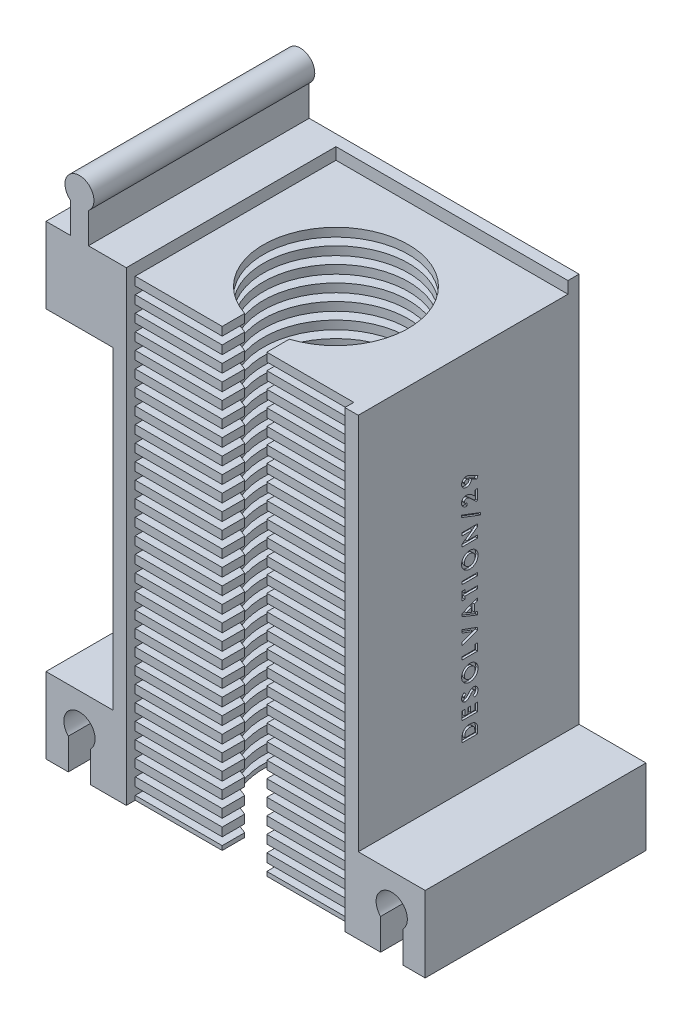
from build123d import *

# Parameters (mm, degrees)
ESQUISSE1_W              = 55
ESQUISSE1_H              = 106.55
BOSS_EXTRU_2_DEPTH       = 49.5
ESQUISSE6_W              = 49
ESQUISSE6_H              = 101.75
ENL_V_MAT_EXTRU_2_DEPTH  = 47
ESQUISSE7_W              = 49
ESQUISSE7_H              = 1.9
BOSS_EXTRU_3_DEPTH       = 45
ESQUISSE8_R              = 16.25
ENL_V_MAT_EXTRU_4_DEPTH  = 107.55
ESQUISSE9_W              = 10
ESQUISSE9_H              = 5.038353904
ENL_V_MAT_EXTRU_5_DEPTH  = 107.55
ESQUISSE11_W             = 55
ESQUISSE11_H             = 49.5
ENL_V_MAT_EXTRU_6_DEPTH  = 4.8
ESQUISSE14_W             = 15
ESQUISSE14_H             = 17.95
BOSS_EXTRU_5_DEPTH       = 49.5
ESQUISSE15_W             = 15
ESQUISSE15_H             = 17.95
BOSS_EXTRU_6_DEPTH       = 49.5
ESQUISSE16_W             = 15
ESQUISSE16_H             = 17
BOSS_EXTRU_7_DEPTH       = 49.5
ESQUISSE17_W             = 15
ESQUISSE17_H             = 17
BOSS_EXTRU_8_DEPTH       = 49.5
ENL_V_MAT_EXTRU_8_DEPTH  = 50.5
BOSS_EXTRU_9_DEPTH       = 49.5
ENL_V_MAT_EXTRU_10_DEPTH = 0.95
ESQUISSE22_W             = 5
ESQUISSE22_H             = 49.5
ENL_V_MAT_EXTRU_11_DEPTH = 0.95
BOSS_EXTRU_10_DEPTH      = 3.6
ESQUISSE24_W             = 49
ESQUISSE24_H             = 1.7
ENL_V_MAT_EXTRU_12_DEPTH = 45
ESQUISSE25_W             = 15
ESQUISSE25_H             = 49.5
ENL_V_MAT_EXTRU_13_DEPTH = 3.6
ESQUISSE26_W             = 5.5
ESQUISSE26_H             = 49.5
BOSS_EXTRU_11_DEPTH      = 3.6
ESQUISSE27_W             = 3.5
ESQUISSE27_H             = 0.628205128
ENL_V_MAT_EXTRU_14_DEPTH = 0.5
ESQUISSE28_W             = 15
ESQUISSE28_H             = 49.5
ENL_V_MAT_EXTRU_15_DEPTH = 30.651737691
ESQUISSE29_W             = 47
ESQUISSE29_H             = 2.65
ENL_V_MAT_EXTRU_16_DEPTH = 68


with BuildPart() as part:
    # Esquisse1 → Boss.-Extru.2 (new body)
    with BuildSketch(Plane.XY):
        with Locations((7.352262443, -28.968325792)):
            Rectangle(ESQUISSE1_W, ESQUISSE1_H)
    extrude(amount=BOSS_EXTRU_2_DEPTH)

    # Esquisse6 → Enlèv. mat.-Extru.2 (cut)
    with BuildSketch(Plane.XY.offset(49.5)):
        with Locations((7.352262443, -31.368325792)):
            Rectangle(ESQUISSE6_W, ESQUISSE6_H)
    extrude(amount=-ENL_V_MAT_EXTRU_2_DEPTH, mode=Mode.SUBTRACT)

    # Esquisse7 → Boss.-Extru.3 (add)
    with BuildSketch(Plane.XY.offset(2.5)):
        with Locations((7.352262443, -81.293325792)):
            Rectangle(ESQUISSE7_W, ESQUISSE7_H)
        with Locations((7.352262443, -77.693325792)):
            Rectangle(ESQUISSE7_W, ESQUISSE7_H)
        with Locations((7.352262443, -74.093325792)):
            Rectangle(ESQUISSE7_W, ESQUISSE7_H)
        with Locations((7.352262443, -70.493325792)):
            Rectangle(ESQUISSE7_W, ESQUISSE7_H)
        with Locations((7.352262443, -66.893325792)):
            Rectangle(ESQUISSE7_W, ESQUISSE7_H)
        with Locations((7.352262443, -63.293325792)):
            Rectangle(ESQUISSE7_W, ESQUISSE7_H)
        with Locations((7.352262443, -59.693325792)):
            Rectangle(ESQUISSE7_W, ESQUISSE7_H)
        with Locations((7.352262443, -56.093325792)):
            Rectangle(ESQUISSE7_W, ESQUISSE7_H)
        with Locations((7.352262443, -52.493325792)):
            Rectangle(ESQUISSE7_W, ESQUISSE7_H)
        with Locations((7.352262443, -48.893325792)):
            Rectangle(ESQUISSE7_W, ESQUISSE7_H)
        with Locations((7.352262443, -45.293325792)):
            Rectangle(ESQUISSE7_W, ESQUISSE7_H)
        with Locations((7.352262443, -41.693325792)):
            Rectangle(ESQUISSE7_W, ESQUISSE7_H)
        with Locations((7.352262443, -38.093325792)):
            Rectangle(ESQUISSE7_W, ESQUISSE7_H)
        with Locations((7.352262443, -34.493325792)):
            Rectangle(ESQUISSE7_W, ESQUISSE7_H)
        with Locations((7.352262443, -30.893325792)):
            Rectangle(ESQUISSE7_W, ESQUISSE7_H)
        with Locations((7.352262443, -27.293325792)):
            Rectangle(ESQUISSE7_W, ESQUISSE7_H)
        with Locations((7.352262443, -23.693325792)):
            Rectangle(ESQUISSE7_W, ESQUISSE7_H)
        with Locations((7.352262443, -20.093325792)):
            Rectangle(ESQUISSE7_W, ESQUISSE7_H)
        with Locations((7.352262443, -16.493325792)):
            Rectangle(ESQUISSE7_W, ESQUISSE7_H)
        with Locations((7.352262443, -12.893325792)):
            Rectangle(ESQUISSE7_W, ESQUISSE7_H)
        with Locations((7.352262443, -9.293325792)):
            Rectangle(ESQUISSE7_W, ESQUISSE7_H)
        with Locations((7.352262443, -5.693325792)):
            Rectangle(ESQUISSE7_W, ESQUISSE7_H)
        with Locations((7.352262443, -2.093325792)):
            Rectangle(ESQUISSE7_W, ESQUISSE7_H)
        with Locations((7.352262443, 1.506674208)):
            Rectangle(ESQUISSE7_W, ESQUISSE7_H)
        with Locations((7.352262443, 5.106674208)):
            Rectangle(ESQUISSE7_W, ESQUISSE7_H)
        with Locations((7.352262443, 8.706674208)):
            Rectangle(ESQUISSE7_W, ESQUISSE7_H)
        with Locations((7.352262443, 12.306674208)):
            Rectangle(ESQUISSE7_W, ESQUISSE7_H)
        with Locations((7.352262443, 15.906674208)):
            Rectangle(ESQUISSE7_W, ESQUISSE7_H)
        with Locations((7.352262443, 19.506674208)):
            Rectangle(ESQUISSE7_W, ESQUISSE7_H)
    extrude(amount=BOSS_EXTRU_3_DEPTH)

    # Esquisse8 → Enlèv. mat.-Extru.4 (cut, through all)
    with BuildSketch(Plane.XZ.offset(82.243325792)):
        with Locations((7.352262443, 27)):
            Circle(ESQUISSE8_R)
    extrude(amount=-ENL_V_MAT_EXTRU_4_DEPTH, mode=Mode.SUBTRACT)

    # Esquisse9 → Enlèv. mat.-Extru.5 (cut, through all)
    with BuildSketch(Plane.XZ.offset(82.243325792)):
        with Locations((7.352262443, 44.980823048)):
            Rectangle(ESQUISSE9_W, ESQUISSE9_H)
    extrude(amount=-ENL_V_MAT_EXTRU_5_DEPTH, mode=Mode.SUBTRACT)

    # Esquisse11 → Enlèv. mat.-Extru.6 (cut)
    with BuildSketch(Plane(origin=(0, 24.306674208, 0), x_dir=(1, 0, 0), z_dir=(0, 1, 0))):
        with Locations((7.352262443, -24.75)):
            Rectangle(ESQUISSE11_W, ESQUISSE11_H)
    extrude(amount=-ENL_V_MAT_EXTRU_6_DEPTH, mode=Mode.SUBTRACT)

    # Esquisse14 → Boss.-Extru.5 (add)
    with BuildSketch(Plane.XY.offset(49.5)):
        with Locations((42.352262443, -73.268325792)):
            Rectangle(ESQUISSE14_W, ESQUISSE14_H)
    extrude(amount=-BOSS_EXTRU_5_DEPTH)

    # Esquisse15 → Boss.-Extru.6 (add)
    with BuildSketch(Plane.XY.offset(49.5)):
        with Locations((-27.647737557, -73.268325792)):
            Rectangle(ESQUISSE15_W, ESQUISSE15_H)
    extrude(amount=-BOSS_EXTRU_6_DEPTH)

    # Esquisse16 → Boss.-Extru.7 (add)
    with BuildSketch(Plane.XY.offset(49.5)):
        with Locations((42.352262443, 11.006674208)):
            Rectangle(ESQUISSE16_W, ESQUISSE16_H)
    extrude(amount=-BOSS_EXTRU_7_DEPTH)

    # Esquisse17 → Boss.-Extru.8 (add)
    with BuildSketch(Plane.XY.offset(49.5)):
        with Locations((-27.647737557, 11.006674208)):
            Rectangle(ESQUISSE17_W, ESQUISSE17_H)
    extrude(amount=-BOSS_EXTRU_8_DEPTH)

    # Esquisse18 → Enlèv. mat.-Extru.8 (cut, through all)
    with BuildSketch(Plane.XY.offset(49.5)):
        with BuildLine():
            Line((44.852262443, -74.343325792), (44.852262443, -82.243325792))
            Line((44.852262443, -82.243325792), (39.852262443, -82.243325792))
            Line((39.852262443, -82.243325792), (39.852262443, -74.343325792))
            ThreePointArc((39.852262443, -74.343325792), (42.352262443, -68.393836049), (44.852262443, -74.343325792))
        make_face()
        with BuildLine():
            Line((-30.147737557, -82.243325792), (-25.147737557, -82.243325792))
            Line((-25.147737557, -82.243325792), (-25.147737557, -74.343325792))
            ThreePointArc((-25.147737557, -74.343325792), (-27.647737557, -68.393836049), (-30.147737557, -74.343325792))
            Line((-30.147737557, -74.343325792), (-30.147737557, -82.243325792))
        make_face()
    extrude(amount=-ENL_V_MAT_EXTRU_8_DEPTH, mode=Mode.SUBTRACT)

    # Esquisse20 → Boss.-Extru.9 (add)
    with BuildSketch(Plane.XY.offset(49.5)):
        with BuildLine():
            Line((-29.647737557, 29.946674208), (-29.647737557, 19.506674208))
            Line((-29.647737557, 19.506674208), (-25.647737557, 19.506674208))
            Line((-25.647737557, 19.506674208), (-25.647737557, 29.946674208))
            ThreePointArc((-25.647737557, 29.946674208), (-27.647737557, 35.7584119), (-29.647737557, 29.946674208))
        make_face()
        with BuildLine():
            Line((40.352262443, 19.506674208), (40.352262443, 29.946674208))
            ThreePointArc((40.352262443, 29.946674208), (42.352262443, 35.7584119), (44.352262443, 29.946674208))
            Line((44.352262443, 29.946674208), (44.352262443, 19.506674208))
            Line((44.352262443, 19.506674208), (40.352262443, 19.506674208))
        make_face()
    extrude(amount=-BOSS_EXTRU_9_DEPTH)

    # Esquisse10 → Enlèv. mat.-Extru.10 (cut)
    with BuildSketch(Plane.XZ.offset(82.243325792)):
        with BuildLine():
            Line((31.852262443, 47.5), (12.352262443, 47.5))
            Line((12.352262443, 47.5), (12.352262443, 42.461646096))
            ThreePointArc((12.352262443, 42.461646096), (7.352262443, 10.75), (2.352262443, 42.461646096))
            Line((2.352262443, 42.461646096), (2.352262443, 47.5))
            Line((2.352262443, 47.5), (-17.147737557, 47.5))
            Line((-17.147737557, 47.5), (-17.147737557, 49.5))
            Line((-17.147737557, 49.5), (-20.147737557, 49.5))
            Line((-20.147737557, 49.5), (-20.147737557, 0))
            Line((-20.147737557, 0), (34.852262443, 0))
            Line((34.852262443, 0), (34.852262443, 49.5))
            Line((34.852262443, 49.5), (31.852262443, 49.5))
            Line((31.852262443, 49.5), (31.852262443, 47.5))
        make_face()
    extrude(amount=-ENL_V_MAT_EXTRU_10_DEPTH, mode=Mode.SUBTRACT)

    # Esquisse22 → Enlèv. mat.-Extru.11 (cut)
    with BuildSketch(Plane.XZ.offset(82.243325792)):
        with Locations((47.352262443, 24.75)):
            Rectangle(ESQUISSE22_W, ESQUISSE22_H)
        with Locations((37.352262443, 24.75)):
            Rectangle(ESQUISSE22_W, ESQUISSE22_H)
        with Locations((-32.647737557, 24.75)):
            Rectangle(ESQUISSE22_W, ESQUISSE22_H)
        with Locations((-22.647737557, 24.75)):
            Rectangle(ESQUISSE22_W, ESQUISSE22_H)
    extrude(amount=-ENL_V_MAT_EXTRU_11_DEPTH, mode=Mode.SUBTRACT)

    # Esquisse23 → Boss.-Extru.10 (add)
    with BuildSketch(Plane(origin=(0, 19.506674208, 0), x_dir=(1, 0, 0), z_dir=(0, 1, 0))):
        with BuildLine():
            Line((40.352262443, -49.5), (40.352262443, 0))
            Line((40.352262443, 0), (-25.647737557, 0))
            Line((-25.647737557, 0), (-25.647737557, -49.5))
            Line((-25.647737557, -49.5), (-17.147737557, -49.5))
            Line((-17.147737557, -49.5), (-17.147737557, -47.5))
            Line((-17.147737557, -47.5), (2.352262443, -47.5))
            Line((2.352262443, -47.5), (2.352262443, -42.461646096))
            ThreePointArc((2.352262443, -42.461646096), (7.352262443, -10.75), (12.352262443, -42.461646096))
            Line((12.352262443, -42.461646096), (12.352262443, -47.5))
            Line((12.352262443, -47.5), (31.852262443, -47.5))
            Line((31.852262443, -47.5), (31.852262443, -49.5))
            Line((31.852262443, -49.5), (40.352262443, -49.5))
        make_face()
    extrude(amount=BOSS_EXTRU_10_DEPTH)

    # Esquisse24 → Enlèv. mat.-Extru.12 (cut)
    with BuildSketch(Plane.XY.offset(47.5)):
        with Locations((7.352262443, 21.306674208)):
            Rectangle(ESQUISSE24_W, ESQUISSE24_H)
    extrude(amount=-ENL_V_MAT_EXTRU_12_DEPTH, mode=Mode.SUBTRACT)

    # Esquisse25 → Enlèv. mat.-Extru.13 (cut)
    with BuildSketch(Plane.XZ.offset(-2.506674208)):
        with Locations((-27.647737557, 24.75)):
            Rectangle(ESQUISSE25_W, ESQUISSE25_H)
        with Locations((42.352262443, 24.75)):
            Rectangle(ESQUISSE25_W, ESQUISSE25_H)
    extrude(amount=-ENL_V_MAT_EXTRU_13_DEPTH, mode=Mode.SUBTRACT)

    # Esquisse26 → Boss.-Extru.11 (add)
    with BuildSketch(Plane(origin=(0, 19.506674208, 0), x_dir=(1, 0, 0), z_dir=(0, 1, 0))):
        with Locations((-32.397737557, -24.75)):
            Rectangle(ESQUISSE26_W, ESQUISSE26_H)
        with Locations((47.102262443, -24.75)):
            Rectangle(ESQUISSE26_W, ESQUISSE26_H)
    extrude(amount=BOSS_EXTRU_11_DEPTH)

    # Esquisse27 → Enlèv. mat.-Extru.14 (cut)
    with BuildSketch(Plane(origin=(34.852262443, 0, 0), x_dir=(0, 0, -1), z_dir=(1, 0, 0))):
        with BuildLine():
            Line((-26.25, -54.768966817), (-26.25, -53.977400311))
            add(Edge.make_bspline(
                [(-26.25, -53.977400311), (-26.249578594, -53.915687085), (-26.248764011, -53.79639472), (-26.239233964, -53.623588275), (-26.225241045, -53.462779541), (-26.203820297, -53.314334816), (-26.178974202, -53.177711122), (-26.145644783, -53.053944802), (-26.107640591, -52.942138404), (-26.062804681, -52.841206053), (-26.010558183, -52.749060361), (-25.952352997, -52.661566177), (-25.886064826, -52.578893855), (-25.812970397, -52.499883605), (-25.731733047, -52.425554968), (-25.643698202, -52.354670132), (-25.547589281, -52.288964674), (-25.445710659, -52.226452461), (-25.337630589, -52.169918483), (-25.224269024, -52.120607434), (-25.106355489, -52.07929927), (-24.983764318, -52.045734248), (-24.856902477, -52.018979051), (-24.72551397, -52.000258979), (-24.589720442, -51.988686044), (-24.4976865, -51.987512066), (-24.450921474, -51.986915535)],
                knots=[0, 0, 0, 0, 0.000185117, 0.000357834, 0.000519065, 0.000669183, 0.000807653, 0.000935374, 0.001053334, 0.001161611, 0.001266144, 0.001370762, 0.001476536, 0.001583695, 0.001693351, 0.00180657, 0.001922483, 0.002042366, 0.002164984, 0.002288073, 0.002412914, 0.002539466, 0.002669135, 0.002801605, 0.002937385, 0.003077654, 0.003077654, 0.003077654, 0.003077654], degree=3))
            add(Edge.make_bspline(
                [(-24.450921474, -51.986915535), (-24.384932979, -51.988477575), (-24.255030763, -51.991552542), (-24.064400757, -52.017454346), (-23.881662884, -52.059346333), (-23.708246589, -52.118250271), (-23.545696172, -52.191275386), (-23.396878133, -52.278512063), (-23.262591281, -52.378681211), (-23.143504152, -52.490615844), (-23.04114743, -52.61181382), (-22.953485402, -52.737762852), (-22.884360039, -52.869690389), (-22.840513664, -52.985935833), (-22.813270001, -53.086737915), (-22.797083391, -53.175231737), (-22.782639367, -53.275819688), (-22.769738179, -53.389168755), (-22.761139953, -53.515267782), (-22.755119024, -53.654138111), (-22.750668347, -53.805597536), (-22.75022862, -53.910790215), (-22.75, -53.965481241)],
                knots=[0, 0, 0, 0, 0.000197895, 0.000389568, 0.000575968, 0.000759549, 0.000938093, 0.001109685, 0.001275991, 0.00143967, 0.001598838, 0.001751113, 0.001899136, 0.002044464, 0.002122868, 0.002212109, 0.002314138, 0.002427722, 0.002554253, 0.002693218, 0.002844719, 0.003008787, 0.003008787, 0.003008787, 0.003008787], degree=3))
            Line((-22.75, -53.965481241), (-22.75, -54.768966817))
            Line((-22.75, -54.768966817), (-26.25, -54.768966817))
        make_face()
        with BuildLine():
            Line((-25.621794872, -54.140761689), (-23.378205128, -54.140761689))
            Line((-23.378205128, -54.140761689), (-23.378205128, -53.812636689))
            add(Edge.make_bspline(
                [(-23.378205128, -53.812636689), (-23.378394152, -53.773601622), (-23.378757652, -53.698535563), (-23.383752105, -53.590024754), (-23.391862503, -53.489884036), (-23.403859003, -53.397982239), (-23.418293863, -53.314108086), (-23.436147882, -53.238567527), (-23.457859729, -53.171211673), (-23.483447361, -53.11148508), (-23.512661318, -53.05695602), (-23.546774213, -53.006439255), (-23.584684458, -52.957684422), (-23.627472703, -52.911592604), (-23.674581701, -52.867992226), (-23.726251594, -52.827140464), (-23.782325449, -52.788492273), (-23.843099544, -52.753039619), (-23.907932147, -52.720642798), (-23.976195242, -52.691903186), (-24.04845732, -52.668073807), (-24.124041919, -52.648268286), (-24.20360709, -52.634114996), (-24.286563503, -52.622405848), (-24.373239826, -52.61636944), (-24.432217292, -52.615540981), (-24.462139423, -52.615120664)],
                knots=[0, 0, 0, 0, 0.000117096, 0.00022518, 0.000325793, 0.00041841, 0.000503133, 0.000581017, 0.00065108, 0.000715155, 0.0007757, 0.00083637, 0.000897801, 0.000960813, 0.001024815, 0.001090185, 0.001158251, 0.001228957, 0.001301074, 0.001375555, 0.001450937, 0.001529162, 0.001609745, 0.001693235, 0.001780402, 0.001870171, 0.001870171, 0.001870171, 0.001870171], degree=3))
            add(Edge.make_bspline(
                [(-24.462139423, -52.615120664), (-24.507993301, -52.615954791), (-24.597404811, -52.617581276), (-24.727617239, -52.633364792), (-24.850078276, -52.658796641), (-24.964473331, -52.695843815), (-25.071529664, -52.741402153), (-25.169867721, -52.799330531), (-25.261099367, -52.866109794), (-25.314608967, -52.918947546), (-25.341346154, -52.945349029)],
                knots=[0, 0, 0, 0, 0.000137507, 0.000268129, 0.000392852, 0.000512141, 0.000628325, 0.00074112, 0.000853862, 0.000966454, 0.000966454, 0.000966454, 0.000966454], degree=3))
            add(Edge.make_bspline(
                [(-25.341346154, -52.945349029), (-25.364130624, -52.971381223), (-25.410665325, -53.024549032), (-25.466425797, -53.117894233), (-25.515416837, -53.220755809), (-25.554261268, -53.335486926), (-25.584981101, -53.460978759), (-25.606167818, -53.597978738), (-25.619782177, -53.7457532), (-25.6211096, -53.848127904), (-25.621794872, -53.900978035)],
                knots=[0, 0, 0, 0, 0.000103595, 0.000211582, 0.000324802, 0.000444978, 0.000574215, 0.000711958, 0.000860493, 0.001019003, 0.001019003, 0.001019003, 0.001019003], degree=3))
            Line((-25.621794872, -53.900978035), (-25.621794872, -54.140761689))
        make_face(mode=Mode.SUBTRACT)
        Polygon((-26.25, -50.470248869), (-26.25, -48.585633484), (-25.621794872, -48.585633484), (-25.621794872, -49.842043741), (-24.948717949, -49.842043741), (-24.948717949, -48.585633484), (-24.320512821, -48.585633484), (-24.320512821, -49.842043741), (-23.378205128, -49.842043741), (-23.378205128, -48.585633484), (-22.75, -48.585633484), (-22.75, -50.470248869), align=None)
        with BuildLine():
            Line((-25.782351763, -45.274095023), (-25.352564103, -45.743846625))
            add(Edge.make_bspline(
                [(-25.352564103, -45.743846625), (-25.380948479, -45.76396877), (-25.435442524, -45.802600481), (-25.508411334, -45.865218455), (-25.57065916, -45.927553677), (-25.621925958, -45.990183645), (-25.661900244, -46.053663487), (-25.690202481, -46.11788301), (-25.708194481, -46.182478138), (-25.710434918, -46.225876092), (-25.711538462, -46.247252074)],
                knots=[0, 0, 0, 0, 0.000104333, 0.000200305, 0.000288057, 0.000368319, 0.000442638, 0.000512332, 0.000578316, 0.000642364, 0.000642364, 0.000642364, 0.000642364], degree=3))
            add(Edge.make_bspline(
                [(-25.711538462, -46.247252074), (-25.710859996, -46.267200818), (-25.709550059, -46.305716602), (-25.695874155, -46.360367956), (-25.673774631, -46.40948143), (-25.643247665, -46.451748774), (-25.606789609, -46.485751934), (-25.567978229, -46.512191421), (-25.525661045, -46.527555458), (-25.49663918, -46.529528504), (-25.482271635, -46.530505279)],
                knots=[0, 0, 0, 0, 5.9744e-05, 0.000115349, 0.000167746, 0.00022048, 0.000270574, 0.000316662, 0.00036057, 0.000403619, 0.000403619, 0.000403619, 0.000403619], degree=3))
            add(Edge.make_bspline(
                [(-25.482271635, -46.530505279), (-25.467703647, -46.529886982), (-25.438365745, -46.528641817), (-25.395367395, -46.516615224), (-25.353353002, -46.498487713), (-25.327776842, -46.481166136), (-25.314703526, -46.47231217)],
                knots=[0, 0, 0, 0, 4.3611e-05, 8.7826e-05, 0.000133031, 0.000180298, 0.000180298, 0.000180298, 0.000180298], degree=3))
            add(Edge.make_bspline(
                [(-25.314703526, -46.47231217), (-25.304570777, -46.464231681), (-25.281111756, -46.445523987), (-25.243396348, -46.41090352), (-25.198817605, -46.365697453), (-25.146449278, -46.311029204), (-25.085794161, -46.247089481), (-25.017865448, -46.172886999), (-24.943323803, -46.087879603), (-24.890772321, -46.028255945), (-24.86318109, -45.996951593)],
                knots=[0, 0, 0, 0, 3.8873e-05, 8.9997e-05, 0.000153455, 0.000229322, 0.000317108, 0.000417848, 0.000531096, 0.000656281, 0.000656281, 0.000656281, 0.000656281], degree=3))
            add(Edge.make_bspline(
                [(-24.86318109, -45.996951593), (-24.837708176, -45.967503382), (-24.789365877, -45.911616794), (-24.720638911, -45.832202055), (-24.659084447, -45.761955316), (-24.604241548, -45.701515443), (-24.558368712, -45.649076348), (-24.51864378, -45.606957294), (-24.486804547, -45.573355671), (-24.467551594, -45.554273887), (-24.459334936, -45.546130279)],
                knots=[0, 0, 0, 0, 0.00011681, 0.000221681, 0.000315075, 0.000396998, 0.000466519, 0.000524062, 0.000570675, 0.000605379, 0.000605379, 0.000605379, 0.000605379], degree=3))
            add(Edge.make_bspline(
                [(-24.459334936, -45.546130279), (-24.425893407, -45.51523371), (-24.361607045, -45.455839654), (-24.262008623, -45.37860103), (-24.164866042, -45.315310748), (-24.068591755, -45.26577726), (-23.970962887, -45.228711575), (-23.869873927, -45.202743909), (-23.764557336, -45.186955273), (-23.692829706, -45.185226056), (-23.656550481, -45.184351433)],
                knots=[0, 0, 0, 0, 0.000136539, 0.000262476, 0.000377607, 0.000483905, 0.000586645, 0.000690207, 0.000796501, 0.000905285, 0.000905285, 0.000905285, 0.000905285], degree=3))
            add(Edge.make_bspline(
                [(-23.656550481, -45.184351433), (-23.62120206, -45.184977938), (-23.551847141, -45.186207165), (-23.450356547, -45.201262831), (-23.353225654, -45.222731334), (-23.261511331, -45.255925385), (-23.173708316, -45.296382164), (-23.091183556, -45.34710033), (-23.013104683, -45.406662795), (-22.940856727, -45.47492696), (-22.87532825, -45.550448565), (-22.816876988, -45.63140365), (-22.76900145, -45.718893919), (-22.728000136, -45.811176844), (-22.698822842, -45.909937255), (-22.675868152, -46.013375185), (-22.662419885, -46.122565757), (-22.660987959, -46.197202332), (-22.66025641, -46.235333003)],
                knots=[0, 0, 0, 0, 0.000105953, 0.000207884, 0.000307206, 0.000403889, 0.000499869, 0.000596786, 0.000693825, 0.000794014, 0.0008944, 0.000993427, 0.001092919, 0.001193084, 0.001295767, 0.001401245, 0.001510733, 0.001625093, 0.001625093, 0.001625093, 0.001625093], degree=3))
            add(Edge.make_bspline(
                [(-22.66025641, -46.235333003), (-22.660787067, -46.265267424), (-22.661838073, -46.324554745), (-22.670430813, -46.411932456), (-22.684268419, -46.496316378), (-22.704207169, -46.577560965), (-22.729126286, -46.656301852), (-22.76093787, -46.731771488), (-22.797508368, -46.804512241), (-22.839623573, -46.874374584), (-22.888564784, -46.940917968), (-22.94241612, -47.006007246), (-23.003786402, -47.067498389), (-23.071484125, -47.126769458), (-23.145924483, -47.183055602), (-23.225977896, -47.238278515), (-23.31315656, -47.289961723), (-23.374312024, -47.321889558), (-23.405548878, -47.338197587)],
                knots=[0, 0, 0, 0, 8.9787e-05, 0.000177831, 0.000263126, 0.00034611, 0.000428593, 0.000510624, 0.000591521, 0.000672684, 0.000755006, 0.00083912, 0.000925881, 0.001015317, 0.001108851, 0.001205697, 0.00130694, 0.001412645, 0.001412645, 0.001412645, 0.001412645], degree=3))
            Line((-23.405548878, -47.338197587), (-23.737179487, -46.785713612))
            add(Edge.make_bspline(
                [(-23.737179487, -46.785713612), (-23.701721473, -46.765314802), (-23.63374543, -46.726208538), (-23.542411001, -46.659939319), (-23.464198182, -46.592049887), (-23.400489388, -46.5209707), (-23.350432751, -46.447566053), (-23.314658806, -46.371481385), (-23.292514774, -46.292663241), (-23.289810476, -46.238975902), (-23.288461538, -46.212195984)],
                knots=[0, 0, 0, 0, 0.000122646, 0.000235123, 0.000337949, 0.000432798, 0.000520693, 0.0006035, 0.000684117, 0.000764351, 0.000764351, 0.000764351, 0.000764351], degree=3))
            add(Edge.make_bspline(
                [(-23.288461538, -46.212195984), (-23.289563154, -46.184956973), (-23.291700449, -46.132109325), (-23.311441996, -46.056676069), (-23.342437673, -45.987516005), (-23.38666423, -45.927734556), (-23.437708399, -45.877115394), (-23.494497371, -45.839755546), (-23.555941668, -45.816285839), (-23.598624918, -45.813804521), (-23.620092147, -45.812556561)],
                knots=[0, 0, 0, 0, 8.1575e-05, 0.000158267, 0.000232307, 0.000307618, 0.000380007, 0.000446905, 0.00051034, 0.000574526, 0.000574526, 0.000574526, 0.000574526], degree=3))
            add(Edge.make_bspline(
                [(-23.620092147, -45.812556561), (-23.640063911, -45.813709001), (-23.680634636, -45.816050074), (-23.74095678, -45.833293689), (-23.801251492, -45.86025072), (-23.850706845, -45.892142789), (-23.892114472, -45.924596963), (-23.927992307, -45.955630472), (-23.967631034, -45.993421078), (-24.011080516, -46.037872959), (-24.058723248, -46.08839879), (-24.110554566, -46.145041133), (-24.166117898, -46.208448602), (-24.20396709, -46.253265126), (-24.223758013, -46.276699189)],
                knots=[0, 0, 0, 0, 5.9859e-05, 0.000121597, 0.000186877, 0.000257482, 0.000297452, 0.000344677, 0.000399728, 0.000461701, 0.000531137, 0.000608059, 0.000692021, 0.000784039, 0.000784039, 0.000784039, 0.000784039], degree=3))
            add(Edge.make_bspline(
                [(-24.223758013, -46.276699189), (-24.261450785, -46.321248313), (-24.333794625, -46.406751566), (-24.440644621, -46.527577916), (-24.540504245, -46.636455362), (-24.634614437, -46.732434437), (-24.721216561, -46.816767369), (-24.801079437, -46.888790932), (-24.874765535, -46.948119143), (-24.962626851, -47.009701418), (-25.0687399, -47.068922242), (-25.196325337, -47.120201939), (-25.324023034, -47.153158574), (-25.4098701, -47.156879161), (-25.452123397, -47.158710407)],
                knots=[0, 0, 0, 0, 0.000175062, 0.000335996, 0.000483855, 0.000618216, 0.0007392, 0.000846451, 0.000940727, 0.001022807, 0.00116813, 0.001304054, 0.001434653, 0.001561236, 0.001561236, 0.001561236, 0.001561236], degree=3))
            add(Edge.make_bspline(
                [(-25.452123397, -47.158710407), (-25.482088506, -47.157951198), (-25.54112299, -47.156455475), (-25.627924828, -47.143113858), (-25.711680407, -47.123173207), (-25.792088406, -47.094217673), (-25.86903224, -47.056622348), (-25.94294889, -47.011018754), (-26.013062404, -46.956339157), (-26.080062459, -46.895502211), (-26.140663498, -46.827665077), (-26.194122447, -46.75547558), (-26.239518366, -46.679250328), (-26.275959011, -46.598695632), (-26.304885676, -46.514469448), (-26.325149965, -46.426358987), (-26.337265806, -46.334529777), (-26.338907372, -46.272062067), (-26.33974359, -46.240240856)],
                knots=[0, 0, 0, 0, 8.9842e-05, 0.000176999, 0.000262874, 0.000347814, 0.000432791, 0.000519374, 0.000607862, 0.00069917, 0.000790526, 0.000880272, 0.00096829, 0.00105614, 0.00114505, 0.001235018, 0.00132694, 0.001422385, 0.001422385, 0.001422385, 0.001422385], degree=3))
            add(Edge.make_bspline(
                [(-26.33974359, -46.240240856), (-26.338235058, -46.199002941), (-26.335229901, -46.116852628), (-26.311729417, -45.995391603), (-26.274775458, -45.876751209), (-26.230185096, -45.781156052), (-26.187011968, -45.70507503), (-26.147199435, -45.646819861), (-26.101765707, -45.587195621), (-26.049430261, -45.527125219), (-25.991909725, -45.465150458), (-25.927878206, -45.40218695), (-25.857994416, -45.337563989), (-25.808007695, -45.295621971), (-25.782351763, -45.274095023)],
                knots=[0, 0, 0, 0, 0.000123638, 0.0002463, 0.000369811, 0.000495611, 0.000561878, 0.000632077, 0.000707101, 0.000786646, 0.000870979, 0.000960715, 0.001055985, 0.001156444, 0.001156444, 0.001156444, 0.001156444], degree=3))
        make_face()
        with BuildLine():
            add(Edge.make_bspline(
                [(-26.33974359, -42.022853035), (-26.338167721, -41.962001434), (-26.3350566, -41.841866592), (-26.309132442, -41.665188325), (-26.266869189, -41.494938823), (-26.208203575, -41.33113496), (-26.131234536, -41.174520936), (-26.039491395, -41.023570349), (-25.928986383, -40.880195073), (-25.803655216, -40.744890444), (-25.667274317, -40.619884252), (-25.520441097, -40.511593951), (-25.366840026, -40.41899487), (-25.205888991, -40.342814829), (-25.037039251, -40.284298219), (-24.860994412, -40.243414326), (-24.677706796, -40.217114909), (-24.552909074, -40.214092592), (-24.489483173, -40.212556561)],
                knots=[0, 0, 0, 0, 0.000182486, 0.000360268, 0.000534396, 0.00070805, 0.00088114, 0.00105706, 0.001237116, 0.001423178, 0.0016098, 0.001791254, 0.001969572, 0.002147089, 0.002324474, 0.002504569, 0.0026886, 0.00287879, 0.00287879, 0.00287879, 0.00287879], degree=3))
            add(Edge.make_bspline(
                [(-24.489483173, -40.212556561), (-24.426772131, -40.214192899), (-24.30319801, -40.217417355), (-24.121596661, -40.242335582), (-23.947447913, -40.283934104), (-23.780397792, -40.341298905), (-23.621288648, -40.416230374), (-23.469456335, -40.507245168), (-23.325421581, -40.615302063), (-23.189791309, -40.737812006), (-23.06584061, -40.871849774), (-22.95732277, -41.014611152), (-22.86539022, -41.164394772), (-22.789684465, -41.321083325), (-22.73257561, -41.485805914), (-22.689870401, -41.656703157), (-22.665166628, -41.835165027), (-22.66190961, -41.956405724), (-22.66025641, -42.017945183)],
                knots=[0, 0, 0, 0, 0.000188089, 0.000370635, 0.000548684, 0.000724515, 0.000899532, 0.001075324, 0.001254672, 0.001438843, 0.001622923, 0.001801572, 0.00197593, 0.002149347, 0.002322529, 0.002498019, 0.002677092, 0.002861679, 0.002861679, 0.002861679, 0.002861679], degree=3))
            add(Edge.make_bspline(
                [(-22.66025641, -42.017945183), (-22.66172221, -42.082312928), (-22.664602305, -42.20878675), (-22.691759654, -42.3939277), (-22.733164649, -42.571055921), (-22.793109119, -42.739686079), (-22.870998612, -42.899687081), (-22.965044231, -43.051776466), (-23.077062596, -43.194810385), (-23.203675043, -43.328312064), (-23.342252759, -43.449250819), (-23.488638503, -43.556006675), (-23.641725246, -43.646056684), (-23.801581713, -43.71940547), (-23.967215196, -43.777230646), (-24.13963425, -43.818019753), (-24.318425406, -43.842114848), (-24.439863931, -43.845471155), (-24.501402244, -43.847171946)],
                knots=[0, 0, 0, 0, 0.000192992, 0.000379203, 0.000560143, 0.000737993, 0.000914849, 0.001093067, 0.001273424, 0.001458907, 0.001644244, 0.001824454, 0.002001698, 0.002176124, 0.002351292, 0.002527132, 0.002706806, 0.002891392, 0.002891392, 0.002891392, 0.002891392], degree=3))
            add(Edge.make_bspline(
                [(-24.501402244, -43.847171946), (-24.542801939, -43.846637984), (-24.625077116, -43.84557682), (-24.747005781, -43.832800024), (-24.866550437, -43.81439328), (-24.983253879, -43.78721462), (-25.098077566, -43.753983661), (-25.209998546, -43.711492182), (-25.31977582, -43.66250229), (-25.426179008, -43.605860667), (-25.527982507, -43.54182707), (-25.626061507, -43.473445763), (-25.717849216, -43.398112983), (-25.804324601, -43.317368295), (-25.885156419, -43.230941799), (-25.960260646, -43.138659263), (-26.030496839, -43.041183532), (-26.094932582, -42.938505642), (-26.151890013, -42.831385042), (-26.202895691, -42.722185532), (-26.244766818, -42.610453326), (-26.279240778, -42.49684322), (-26.306944788, -42.38151578), (-26.325356866, -42.263554362), (-26.338128579, -42.143961559), (-26.339203975, -42.063318348), (-26.33974359, -42.022853035)],
                knots=[0, 0, 0, 0, 0.000124148, 0.000246724, 0.000367409, 0.000486805, 0.000605941, 0.000725748, 0.00084563, 0.000966388, 0.001087007, 0.001206249, 0.001324841, 0.0014429, 0.001560959, 0.001679551, 0.001799606, 0.001921192, 0.002042899, 0.002163361, 0.002282513, 0.002400505, 0.002519378, 0.002637986, 0.002758469, 0.002879813, 0.002879813, 0.002879813, 0.002879813], degree=3))
        make_face()
        with BuildLine():
            add(Edge.make_bspline(
                [(-25.711538462, -42.032668741), (-25.710439594, -42.073621987), (-25.708270869, -42.154447307), (-25.691748119, -42.273003332), (-25.66535941, -42.386821303), (-25.627135687, -42.495270281), (-25.578486588, -42.598820295), (-25.5195821, -42.697654906), (-25.448397447, -42.790405459), (-25.368754215, -42.878308693), (-25.280013352, -42.957714801), (-25.184912425, -43.027872602), (-25.083610251, -43.086583381), (-24.977047904, -43.135754027), (-24.864027118, -43.172768625), (-24.745433197, -43.199133013), (-24.621061798, -43.215794323), (-24.536277978, -43.217894501), (-24.492988782, -43.218966817)],
                knots=[0, 0, 0, 0, 0.000122824, 0.000242406, 0.000358388, 0.000472807, 0.000586661, 0.000701131, 0.000817238, 0.000936842, 0.001056496, 0.001173871, 0.001290754, 0.001407153, 0.001525327, 0.001646775, 0.001771221, 0.00190105, 0.00190105, 0.00190105, 0.00190105], degree=3))
            add(Edge.make_bspline(
                [(-24.492988782, -43.218966817), (-24.445016002, -43.217541828), (-24.350997301, -43.214749085), (-24.213821902, -43.195189856), (-24.084150974, -43.161427616), (-23.962628361, -43.113548335), (-23.848569642, -43.052866041), (-23.742617566, -42.978538736), (-23.64427387, -42.890578429), (-23.586841652, -42.822852092), (-23.557692308, -42.788478035)],
                knots=[0, 0, 0, 0, 0.000143901, 0.000282022, 0.000414667, 0.000544995, 0.00067297, 0.000801345, 0.000932411, 0.001067493, 0.001067493, 0.001067493, 0.001067493], degree=3))
            add(Edge.make_bspline(
                [(-23.557692308, -42.788478035), (-23.536158968, -42.760316757), (-23.493577439, -42.704628678), (-23.439000474, -42.61573838), (-23.392222571, -42.524198877), (-23.354426578, -42.429319388), (-23.324696886, -42.331300293), (-23.303877671, -42.230155034), (-23.290811814, -42.126026926), (-23.289250196, -42.055610619), (-23.288461538, -42.020048548)],
                knots=[0, 0, 0, 0, 0.000106293, 0.000210192, 0.000312412, 0.000414354, 0.000516162, 0.000619291, 0.000723822, 0.000830475, 0.000830475, 0.000830475, 0.000830475], degree=3))
            add(Edge.make_bspline(
                [(-23.288461538, -42.020048548), (-23.289571354, -41.979800318), (-23.291754951, -41.90061066), (-23.308051007, -41.784249849), (-23.335754907, -41.672827233), (-23.373360596, -41.565296451), (-23.423815369, -41.463147933), (-23.483422698, -41.364756684), (-23.555069551, -41.271837973), (-23.636390935, -41.184425718), (-23.725443642, -41.104248434), (-23.820575808, -41.033516927), (-23.920902252, -40.973840352), (-24.026406378, -40.92504465), (-24.136972237, -40.886821477), (-24.25293853, -40.860723853), (-24.373776907, -40.843935536), (-24.456006023, -40.841832868), (-24.497896635, -40.840761689)],
                knots=[0, 0, 0, 0, 0.000120723, 0.000237527, 0.000351629, 0.000464725, 0.000578551, 0.000692784, 0.000809316, 0.00092987, 0.001050514, 0.001168305, 0.00128494, 0.001400065, 0.00151647, 0.001635184, 0.001756155, 0.001881781, 0.001881781, 0.001881781, 0.001881781], degree=3))
            add(Edge.make_bspline(
                [(-24.497896635, -40.840761689), (-24.539547888, -40.841866123), (-24.621532028, -40.844040033), (-24.742037961, -40.860428234), (-24.857356876, -40.88767306), (-24.967786038, -40.926178708), (-25.07390519, -40.974148733), (-25.17479331, -41.03440707), (-25.270363111, -41.10564759), (-25.360046419, -41.186567956), (-25.442465159, -41.274630313), (-25.513988235, -41.369177871), (-25.576139881, -41.467560561), (-25.624826882, -41.572036945), (-25.663615736, -41.680469217), (-25.692180398, -41.793519118), (-25.708154796, -41.911614809), (-25.710400519, -41.991957751), (-25.711538462, -42.032668741)],
                knots=[0, 0, 0, 0, 0.000124926, 0.000245897, 0.000364088, 0.00047983, 0.000596229, 0.000712864, 0.000831635, 0.000953269, 0.001074815, 0.001192886, 0.001308453, 0.00142324, 0.001537892, 0.001653524, 0.001772411, 0.001894535, 0.001894535, 0.001894535, 0.001894535], degree=3))
        make_face(mode=Mode.SUBTRACT)
        Polygon((-26.25, -38.695889894), (-26.25, -38.067684766), (-23.378205128, -38.067684766), (-23.378205128, -37.080505279), (-22.75, -37.080505279), (-22.75, -38.695889894), align=None)
        Polygon((-26.25, -35.945248869), (-26.25, -35.274275311), (-23.763822115, -34.374736048), (-26.25, -33.47309342), (-26.25, -32.804223228), (-22.75, -34.073253676), (-22.75, -34.678321785), align=None)
        Polygon((-26.25, -30.277240055), (-26.25, -29.694607843), (-22.75, -28.281146305), (-22.75, -28.952119862), (-23.467948718, -29.224155119), (-23.467948718, -30.749095023), (-22.75, -31.021130279), (-22.75, -31.691402715), align=None)
        Polygon((-25.311197917, -29.98627451), (-24.096153846, -30.510713612), (-24.096153846, -29.461835407), align=None, mode=Mode.SUBTRACT)
        Polygon((-26.25, -27.235633484), (-26.25, -25.3510181), (-25.621794872, -25.3510181), (-25.621794872, -25.979223228), (-22.75, -25.979223228), (-22.75, -26.607428356), (-25.621794872, -26.607428356), (-25.621794872, -27.235633484), align=None)
        with Locations((-24.5, -23.744607843)):
            Rectangle(ESQUISSE27_W, ESQUISSE27_H)
        with BuildLine():
            add(Edge.make_bspline(
                [(-26.33974359, -20.089519702), (-26.338167721, -20.028668101), (-26.3350566, -19.908533258), (-26.309132442, -19.731854992), (-26.266869189, -19.56160549), (-26.208203575, -19.397801627), (-26.131234536, -19.241187603), (-26.039491395, -19.090237016), (-25.928986383, -18.94686174), (-25.803655216, -18.811557111), (-25.667274317, -18.686550918), (-25.520441097, -18.578260618), (-25.366840026, -18.485661537), (-25.205888991, -18.409481496), (-25.037039251, -18.350964886), (-24.860994412, -18.310080992), (-24.677706796, -18.283781576), (-24.552909074, -18.280759259), (-24.489483173, -18.279223228)],
                knots=[0, 0, 0, 0, 0.000182486, 0.000360268, 0.000534396, 0.00070805, 0.00088114, 0.00105706, 0.001237116, 0.001423178, 0.0016098, 0.001791254, 0.001969572, 0.002147089, 0.002324474, 0.002504569, 0.0026886, 0.00287879, 0.00287879, 0.00287879, 0.00287879], degree=3))
            add(Edge.make_bspline(
                [(-24.489483173, -18.279223228), (-24.426772131, -18.280859566), (-24.30319801, -18.284084022), (-24.121596661, -18.309002249), (-23.947447913, -18.350600771), (-23.780397792, -18.407965572), (-23.621288648, -18.48289704), (-23.469456335, -18.573911835), (-23.325421581, -18.681968729), (-23.189791309, -18.804478673), (-23.06584061, -18.938516441), (-22.95732277, -19.081277818), (-22.86539022, -19.231061438), (-22.789684465, -19.387749992), (-22.73257561, -19.552472581), (-22.689870401, -19.723369824), (-22.665166628, -19.901831693), (-22.66190961, -20.02307239), (-22.66025641, -20.08461185)],
                knots=[0, 0, 0, 0, 0.000188089, 0.000370635, 0.000548684, 0.000724515, 0.000899532, 0.001075324, 0.001254672, 0.001438843, 0.001622923, 0.001801572, 0.00197593, 0.002149347, 0.002322529, 0.002498019, 0.002677092, 0.002861679, 0.002861679, 0.002861679, 0.002861679], degree=3))
            add(Edge.make_bspline(
                [(-22.66025641, -20.08461185), (-22.66172221, -20.148979595), (-22.664602305, -20.275453417), (-22.691759654, -20.460594366), (-22.733164649, -20.637722588), (-22.793109119, -20.806352745), (-22.870998612, -20.966353748), (-22.965044231, -21.118443132), (-23.077062596, -21.261477051), (-23.203675043, -21.39497873), (-23.342252759, -21.515917486), (-23.488638503, -21.622673342), (-23.641725246, -21.712723351), (-23.801581713, -21.786072137), (-23.967215196, -21.843897313), (-24.13963425, -21.88468642), (-24.318425406, -21.908781515), (-24.439863931, -21.912137822), (-24.501402244, -21.913838612)],
                knots=[0, 0, 0, 0, 0.000192992, 0.000379203, 0.000560143, 0.000737993, 0.000914849, 0.001093067, 0.001273424, 0.001458907, 0.001644244, 0.001824454, 0.002001698, 0.002176124, 0.002351292, 0.002527132, 0.002706806, 0.002891392, 0.002891392, 0.002891392, 0.002891392], degree=3))
            add(Edge.make_bspline(
                [(-24.501402244, -21.913838612), (-24.542801939, -21.91330465), (-24.625077116, -21.912243487), (-24.747005781, -21.899466691), (-24.866550437, -21.881059946), (-24.983253879, -21.853881286), (-25.098077566, -21.820650328), (-25.209998546, -21.778158849), (-25.31977582, -21.729168957), (-25.426179008, -21.672527334), (-25.527982507, -21.608493737), (-25.626061507, -21.54011243), (-25.717849216, -21.46477965), (-25.804324601, -21.384034962), (-25.885156419, -21.297608466), (-25.960260646, -21.20532593), (-26.030496839, -21.107850198), (-26.094932582, -21.005172309), (-26.151890013, -20.898051708), (-26.202895691, -20.788852199), (-26.244766818, -20.677119992), (-26.279240778, -20.563509887), (-26.306944788, -20.448182447), (-26.325356866, -20.330221029), (-26.338128579, -20.210628226), (-26.339203975, -20.129985015), (-26.33974359, -20.089519702)],
                knots=[0, 0, 0, 0, 0.000124148, 0.000246724, 0.000367409, 0.000486805, 0.000605941, 0.000725748, 0.00084563, 0.000966388, 0.001087007, 0.001206249, 0.001324841, 0.0014429, 0.001560959, 0.001679551, 0.001799606, 0.001921192, 0.002042899, 0.002163361, 0.002282513, 0.002400505, 0.002519378, 0.002637986, 0.002758469, 0.002879813, 0.002879813, 0.002879813, 0.002879813], degree=3))
        make_face()
        with BuildLine():
            add(Edge.make_bspline(
                [(-25.711538462, -20.099335407), (-25.710439594, -20.140288654), (-25.708270869, -20.221113974), (-25.691748119, -20.339669999), (-25.66535941, -20.453487969), (-25.627135687, -20.561936948), (-25.578486588, -20.665486962), (-25.5195821, -20.764321573), (-25.448397447, -20.857072126), (-25.368754215, -20.94497536), (-25.280013352, -21.024381468), (-25.184912425, -21.094539269), (-25.083610251, -21.153250048), (-24.977047904, -21.202420693), (-24.864027118, -21.239435291), (-24.745433197, -21.26579968), (-24.621061798, -21.282460989), (-24.536277978, -21.284561168), (-24.492988782, -21.285633484)],
                knots=[0, 0, 0, 0, 0.000122824, 0.000242406, 0.000358388, 0.000472807, 0.000586661, 0.000701131, 0.000817238, 0.000936842, 0.001056496, 0.001173871, 0.001290754, 0.001407153, 0.001525327, 0.001646775, 0.001771221, 0.00190105, 0.00190105, 0.00190105, 0.00190105], degree=3))
            add(Edge.make_bspline(
                [(-24.492988782, -21.285633484), (-24.445016002, -21.284208495), (-24.350997301, -21.281415751), (-24.213821902, -21.261856523), (-24.084150974, -21.228094283), (-23.962628361, -21.180215002), (-23.848569642, -21.119532708), (-23.742617566, -21.045205402), (-23.64427387, -20.957245096), (-23.586841652, -20.889518759), (-23.557692308, -20.855144702)],
                knots=[0, 0, 0, 0, 0.000143901, 0.000282022, 0.000414667, 0.000544995, 0.00067297, 0.000801345, 0.000932411, 0.001067493, 0.001067493, 0.001067493, 0.001067493], degree=3))
            add(Edge.make_bspline(
                [(-23.557692308, -20.855144702), (-23.536158968, -20.826983424), (-23.493577439, -20.771295345), (-23.439000474, -20.682405047), (-23.392222571, -20.590865544), (-23.354426578, -20.495986054), (-23.324696886, -20.39796696), (-23.303877671, -20.296821701), (-23.290811814, -20.192693593), (-23.289250196, -20.122277286), (-23.288461538, -20.086715215)],
                knots=[0, 0, 0, 0, 0.000106293, 0.000210192, 0.000312412, 0.000414354, 0.000516162, 0.000619291, 0.000723822, 0.000830475, 0.000830475, 0.000830475, 0.000830475], degree=3))
            add(Edge.make_bspline(
                [(-23.288461538, -20.086715215), (-23.289571354, -20.046466985), (-23.291754951, -19.967277327), (-23.308051007, -19.850916516), (-23.335754907, -19.739493899), (-23.373360596, -19.631963118), (-23.423815369, -19.5298146), (-23.483422698, -19.431423351), (-23.555069551, -19.338504639), (-23.636390935, -19.251092384), (-23.725443642, -19.170915101), (-23.820575808, -19.100183594), (-23.920902252, -19.040507018), (-24.026406378, -18.991711317), (-24.136972237, -18.953488143), (-24.25293853, -18.92739052), (-24.373776907, -18.910602202), (-24.456006023, -18.908499534), (-24.497896635, -18.907428356)],
                knots=[0, 0, 0, 0, 0.000120723, 0.000237527, 0.000351629, 0.000464725, 0.000578551, 0.000692784, 0.000809316, 0.00092987, 0.001050514, 0.001168305, 0.00128494, 0.001400065, 0.00151647, 0.001635184, 0.001756155, 0.001881781, 0.001881781, 0.001881781, 0.001881781], degree=3))
            add(Edge.make_bspline(
                [(-24.497896635, -18.907428356), (-24.539547888, -18.90853279), (-24.621532028, -18.910706699), (-24.742037961, -18.9270949), (-24.857356876, -18.954339727), (-24.967786038, -18.992845375), (-25.07390519, -19.040815399), (-25.17479331, -19.101073737), (-25.270363111, -19.172314256), (-25.360046419, -19.253234622), (-25.442465159, -19.341296979), (-25.513988235, -19.435844538), (-25.576139881, -19.534227228), (-25.624826882, -19.638703612), (-25.663615736, -19.747135883), (-25.692180398, -19.860185784), (-25.708154796, -19.978281476), (-25.710400519, -20.058624417), (-25.711538462, -20.099335407)],
                knots=[0, 0, 0, 0, 0.000124926, 0.000245897, 0.000364088, 0.00047983, 0.000596229, 0.000712864, 0.000831635, 0.000953269, 0.001074815, 0.001192886, 0.001308453, 0.00142324, 0.001537892, 0.001653524, 0.001772411, 0.001894535, 0.001894535, 0.001894535, 0.001894535], degree=3))
        make_face(mode=Mode.SUBTRACT)
        Polygon((-26.25, -16.762556561), (-26.25, -16.196751273), (-23.946814904, -14.608710407), (-26.25, -14.608710407), (-26.25, -13.980505279), (-22.75, -13.980505279), (-22.75, -14.550517298), (-25.046173878, -16.134351433), (-22.75, -16.134351433), (-22.75, -16.762556561), align=None)
        Polygon((-22.121794872, -12.598453997), (-26.33974359, -10.987977234), (-26.33974359, -10.511915535), (-22.121794872, -12.122392298), align=None)
        with BuildLine():
            Line((-25.083333333, -8.748453997), (-25.083333333, -9.376659125))
            add(Edge.make_bspline(
                [(-25.083333333, -9.376659125), (-25.130854225, -9.373947069), (-25.223707194, -9.368647873), (-25.358570766, -9.347545894), (-25.486033191, -9.31934262), (-25.605711269, -9.281380317), (-25.717655278, -9.234621225), (-25.821494412, -9.177901564), (-25.917972725, -9.11291478), (-26.00539818, -9.038350943), (-26.083996324, -8.957236239), (-26.152708884, -8.869778617), (-26.210230283, -8.776226513), (-26.257415349, -8.677205488), (-26.295169479, -8.573104486), (-26.320397882, -8.462871713), (-26.337486499, -8.34747983), (-26.33898158, -8.26848404), (-26.33974359, -8.228221625)],
                knots=[0, 0, 0, 0, 0.000142716, 0.000278858, 0.000408976, 0.000534035, 0.000655007, 0.000772346, 0.00088844, 0.001003349, 0.001116402, 0.001226781, 0.001336329, 0.001445148, 0.001555367, 0.001667776, 0.001783885, 0.001904578, 0.001904578, 0.001904578, 0.001904578], degree=3))
            add(Edge.make_bspline(
                [(-26.33974359, -8.228221625), (-26.338305172, -8.178777888), (-26.335495808, -8.082209714), (-26.308364005, -7.942354907), (-26.266816094, -7.811039237), (-26.206452711, -7.689659528), (-26.130333998, -7.578426815), (-26.039398207, -7.477959516), (-25.932540626, -7.39021706), (-25.81283848, -7.31588374), (-25.685837603, -7.254414001), (-25.55475327, -7.210925157), (-25.422968709, -7.182491022), (-25.33424216, -7.179451274), (-25.290164263, -7.177941176)],
                knots=[0, 0, 0, 0, 0.000148176, 0.000289401, 0.00042576, 0.000560275, 0.000694458, 0.000828966, 0.000965417, 0.001107812, 0.001250813, 0.001387611, 0.0015214, 0.001653479, 0.001653479, 0.001653479, 0.001653479], degree=3))
            add(Edge.make_bspline(
                [(-25.290164263, -7.177941176), (-25.263502321, -7.178528375), (-25.209838418, -7.179710259), (-25.12863176, -7.187928059), (-25.045913288, -7.200256387), (-24.961753913, -7.218844486), (-24.876130087, -7.242025424), (-24.788785397, -7.270147042), (-24.70021573, -7.303862645), (-24.609421581, -7.342605694), (-24.516118882, -7.388839295), (-24.41886483, -7.442618245), (-24.317762959, -7.505740496), (-24.211821602, -7.576151228), (-24.102658361, -7.656620418), (-23.989061065, -7.745016512), (-23.87120871, -7.841784473), (-23.792395337, -7.910410993), (-23.751903045, -7.945669542)],
                knots=[0, 0, 0, 0, 7.9977e-05, 0.000160974, 0.000244663, 0.00033075, 0.000419361, 0.000510712, 0.000605902, 0.000703579, 0.00080674, 0.00091815, 0.001036838, 0.001164207, 0.001299674, 0.001443567, 0.001595999, 0.001757068, 0.001757068, 0.001757068, 0.001757068], degree=3))
            Line((-23.751903045, -7.945669542), (-23.333333333, -8.310953997))
            Line((-23.333333333, -8.310953997), (-23.333333333, -7.133069382))
            Line((-23.333333333, -7.133069382), (-22.75, -7.133069382))
            Line((-22.75, -7.133069382), (-22.75, -9.466402715))
            Line((-22.75, -9.466402715), (-23.068309295, -9.466402715))
            Line((-23.068309295, -9.466402715), (-24.171173878, -8.430144702))
            add(Edge.make_bspline(
                [(-24.171173878, -8.430144702), (-24.20334446, -8.400141895), (-24.265649338, -8.342035354), (-24.357155907, -8.25936345), (-24.443974712, -8.184525149), (-24.527112566, -8.119193822), (-24.603754527, -8.059416739), (-24.676797956, -8.009408812), (-24.74418582, -7.965858034), (-24.826328946, -7.920364646), (-24.923559297, -7.876166616), (-25.035503417, -7.835637728), (-25.142571242, -7.81118021), (-25.212463844, -7.807778308), (-25.24599359, -7.806146305)],
                knots=[0, 0, 0, 0, 0.000131967, 0.000255582, 0.000369957, 0.000475731, 0.00057277, 0.000661456, 0.000741202, 0.000813387, 0.000942958, 0.001061149, 0.001170202, 0.001270758, 0.001270758, 0.001270758, 0.001270758], degree=3))
            add(Edge.make_bspline(
                [(-25.24599359, -7.806146305), (-25.278432191, -7.807363294), (-25.341287182, -7.809721405), (-25.430698073, -7.835635138), (-25.511650506, -7.875781593), (-25.581725534, -7.932353617), (-25.639310831, -8.000880056), (-25.682141156, -8.080068794), (-25.706854058, -8.169274209), (-25.709947231, -8.231808904), (-25.711538462, -8.263978837)],
                knots=[0, 0, 0, 0, 9.7062e-05, 0.000188073, 0.000276808, 0.000366596, 0.000456186, 0.000543702, 0.000634713, 0.000731135, 0.000731135, 0.000731135, 0.000731135], degree=3))
            add(Edge.make_bspline(
                [(-25.711538462, -8.263978837), (-25.710950642, -8.280598234), (-25.709793424, -8.313316186), (-25.702090139, -8.361409018), (-25.688513903, -8.407172802), (-25.670323658, -8.451116916), (-25.646212358, -8.492772377), (-25.616491338, -8.532034114), (-25.581915879, -8.569315802), (-25.542594092, -8.604446451), (-25.498710967, -8.636419928), (-25.450667285, -8.664818653), (-25.39849287, -8.688299671), (-25.342876502, -8.708973213), (-25.283220817, -8.724917637), (-25.219882848, -8.736527156), (-25.152965636, -8.745353098), (-25.106966346, -8.74740156), (-25.083333333, -8.748453997)],
                knots=[0, 0, 0, 0, 4.9859e-05, 9.8155e-05, 0.000145635, 0.000192772, 0.000240515, 0.000289593, 0.000340201, 0.000392836, 0.000447528, 0.000502841, 0.000559939, 0.000618941, 0.00068068, 0.000744897, 0.000812032, 0.000882971, 0.000882971, 0.000882971, 0.000882971], degree=3))
        make_face()
        with BuildLine():
            Line((-22.66025641, -4.660072587), (-22.940705128, -5.216763292))
            Line((-22.940705128, -5.216763292), (-24.141025641, -4.60678733))
            add(Edge.make_bspline(
                [(-24.141025641, -4.60678733), (-24.141944291, -4.642826055), (-24.143747823, -4.713578792), (-24.158733038, -4.817757621), (-24.18431911, -4.917377667), (-24.218362242, -5.013630475), (-24.264069316, -5.105120508), (-24.318440512, -5.193325104), (-24.384763371, -5.275941173), (-24.458199348, -5.354947325), (-24.539588601, -5.426414443), (-24.626551539, -5.489531865), (-24.718251162, -5.542977201), (-24.815303675, -5.585880868), (-24.916741872, -5.619577592), (-25.022963667, -5.644430761), (-25.134377636, -5.658335807), (-25.21019924, -5.660283162), (-25.248798077, -5.66127451)],
                knots=[0, 0, 0, 0, 0.000108084, 0.000212196, 0.000314904, 0.000416257, 0.00051785, 0.000621153, 0.000726492, 0.00083512, 0.00094441, 0.001050856, 0.00115704, 0.001262185, 0.001368608, 0.001477284, 0.001588945, 0.001704735, 0.001704735, 0.001704735, 0.001704735], degree=3))
            add(Edge.make_bspline(
                [(-25.248798077, -5.66127451), (-25.286239523, -5.660356845), (-25.360017117, -5.658548606), (-25.468290116, -5.643501335), (-25.572280734, -5.618810969), (-25.672017607, -5.58461158), (-25.766992878, -5.540076248), (-25.85777246, -5.486269043), (-25.944009135, -5.422388435), (-26.024579069, -5.3489589), (-26.098627223, -5.269399325), (-26.162357853, -5.183807611), (-26.217982113, -5.095476878), (-26.261929693, -5.001977373), (-26.297648374, -4.905046164), (-26.321801472, -4.803350332), (-26.33702242, -4.697928871), (-26.338829275, -4.62623788), (-26.33974359, -4.589960407)],
                knots=[0, 0, 0, 0, 0.000112287, 0.000221259, 0.000327205, 0.000432525, 0.000536976, 0.000641346, 0.00074862, 0.00085832, 0.000967976, 0.001074126, 0.001178025, 0.001280573, 0.001383483, 0.001487384, 0.001593578, 0.001702362, 0.001702362, 0.001702362, 0.001702362], degree=3))
            add(Edge.make_bspline(
                [(-26.33974359, -4.589960407), (-26.338962647, -4.552036591), (-26.337427029, -4.477464538), (-26.320493509, -4.368297572), (-26.294490869, -4.263864466), (-26.25925732, -4.163677584), (-26.211186547, -4.069326271), (-26.154714859, -3.979012744), (-26.086329805, -3.894487325), (-26.00939557, -3.815316654), (-25.925002174, -3.744042609), (-25.837392729, -3.680497766), (-25.746297301, -3.626482608), (-25.651652454, -3.58333541), (-25.554108501, -3.549027596), (-25.453449657, -3.525651036), (-25.349774869, -3.510090433), (-25.279471063, -3.508322904), (-25.243890224, -3.507428356)],
                knots=[0, 0, 0, 0, 0.000113688, 0.000223552, 0.000330511, 0.000436297, 0.000541337, 0.00064754, 0.000755285, 0.000866842, 0.000978252, 0.001086246, 0.00119122, 0.001295376, 0.001397816, 0.001500872, 0.001604983, 0.001711666, 0.001711666, 0.001711666, 0.001711666], degree=3))
            add(Edge.make_bspline(
                [(-25.243890224, -3.507428356), (-25.216754171, -3.507919657), (-25.162096058, -3.508909247), (-25.080353405, -3.518518189), (-24.998400725, -3.533297714), (-24.929371146, -3.550533932), (-24.870947437, -3.567871301), (-24.821525208, -3.585899267), (-24.766453141, -3.607641837), (-24.705646485, -3.632807623), (-24.639406468, -3.661598812), (-24.567963291, -3.694996789), (-24.490222216, -3.730892125), (-24.437065488, -3.757354882), (-24.409555288, -3.771050151)],
                knots=[0, 0, 0, 0, 8.1378e-05, 0.000163915, 0.000246567, 0.00033108, 0.000377216, 0.000429331, 0.000488831, 0.000554844, 0.000626746, 0.000705488, 0.000791429, 0.000883615, 0.000883615, 0.000883615, 0.000883615], degree=3))
            Line((-24.409555288, -3.771050151), (-22.66025641, -4.660072587))
        make_face()
        with BuildLine():
            add(Edge.make_bspline(
                [(-24.724358974, -4.575937971), (-24.726128284, -4.545834489), (-24.729585115, -4.4870191), (-24.756396642, -4.402577284), (-24.802138428, -4.326701921), (-24.86375592, -4.26014586), (-24.937831792, -4.204740788), (-25.021995541, -4.164142869), (-25.114906789, -4.139529246), (-25.179701159, -4.136957016), (-25.213040865, -4.135633484)],
                knots=[0, 0, 0, 0, 9.0205e-05, 0.000176241, 0.000262695, 0.000354002, 0.000446691, 0.00053857, 0.000632782, 0.000732639, 0.000732639, 0.000732639, 0.000732639], degree=3))
            add(Edge.make_bspline(
                [(-25.213040865, -4.135633484), (-25.247078143, -4.137216105), (-25.313288776, -4.14029468), (-25.408584452, -4.165331807), (-25.494726092, -4.208115219), (-25.569606899, -4.266319605), (-25.632272569, -4.334272467), (-25.678048153, -4.410260918), (-25.706354307, -4.492439802), (-25.709798478, -4.549310465), (-25.711538462, -4.578041337)],
                knots=[0, 0, 0, 0, 0.00010201, 0.000198434, 0.000293127, 0.000388627, 0.000481442, 0.000568858, 0.000653109, 0.000739131, 0.000739131, 0.000739131, 0.000739131], degree=3))
            add(Edge.make_bspline(
                [(-25.711538462, -4.578041337), (-25.70983883, -4.608405051), (-25.706501617, -4.668023956), (-25.678311942, -4.753596641), (-25.633303926, -4.832123949), (-25.571197278, -4.901739669), (-25.496627884, -4.96059212), (-25.410210571, -5.00243929), (-25.315530351, -5.028668349), (-25.249207935, -5.031575993), (-25.215144231, -5.033069382)],
                knots=[0, 0, 0, 0, 9.0903e-05, 0.000178487, 0.000267364, 0.000360758, 0.000456686, 0.00055044, 0.000647045, 0.000749055, 0.000749055, 0.000749055, 0.000749055], degree=3))
            add(Edge.make_bspline(
                [(-25.215144231, -5.033069382), (-25.181559061, -5.031518033), (-25.116239412, -5.028500822), (-25.022698276, -5.003086987), (-24.937706252, -4.962080743), (-24.863528046, -4.904883869), (-24.801597021, -4.836101143), (-24.756386932, -4.756815815), (-24.729510204, -4.668778876), (-24.72610696, -4.60744202), (-24.724358974, -4.575937971)],
                knots=[0, 0, 0, 0, 0.000100613, 0.000195681, 0.000288497, 0.000382031, 0.0004749, 0.000564385, 0.000653769, 0.000748161, 0.000748161, 0.000748161, 0.000748161], degree=3))
        make_face(mode=Mode.SUBTRACT)
    extrude(amount=-ENL_V_MAT_EXTRU_14_DEPTH, mode=Mode.SUBTRACT)

    # Esquisse28 → Enlèv. mat.-Extru.15 (cut, through all)
    with BuildSketch(Plane.XZ.offset(-6.106674208)):
        with Locations((42.352262443, 24.75)):
            Rectangle(ESQUISSE28_W, ESQUISSE28_H)
    extrude(amount=-ENL_V_MAT_EXTRU_15_DEPTH, mode=Mode.SUBTRACT)

    # Esquisse29 → Enlèv. mat.-Extru.16 (cut, through all)
    with BuildSketch(Plane(origin=(-17.147737557, 0, 0), x_dir=(0, 0, -1), z_dir=(1, 0, 0))):
        with Locations((-26, 21.781674208)):
            Rectangle(ESQUISSE29_W, ESQUISSE29_H)
    extrude(amount=ENL_V_MAT_EXTRU_16_DEPTH, mode=Mode.SUBTRACT)


solid = part.part
